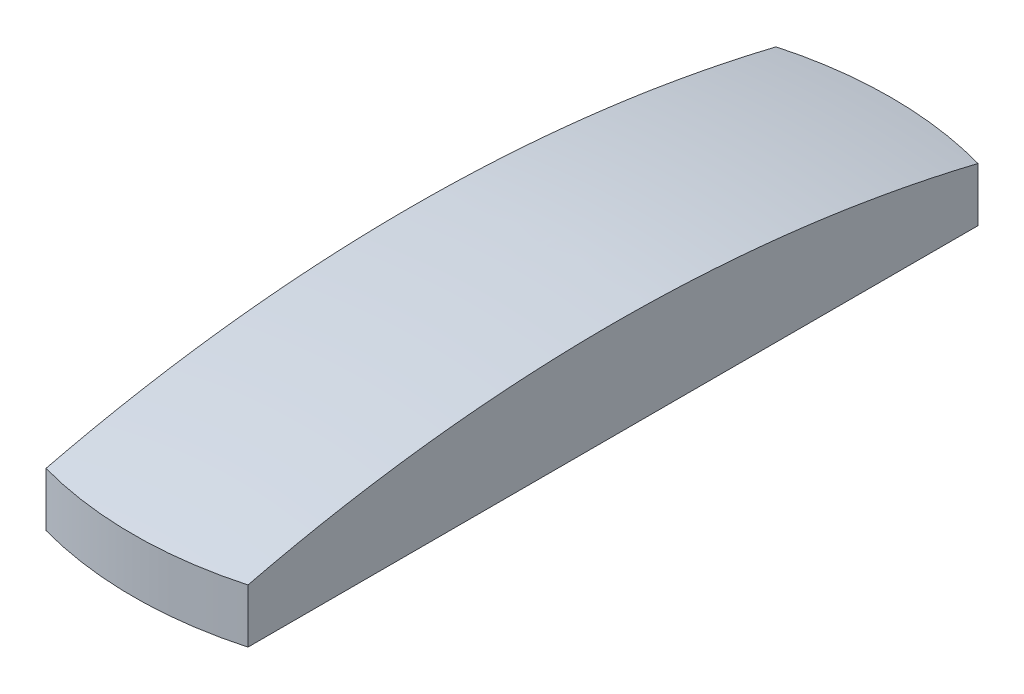
from build123d import *

# Parameters (mm, degrees)
CUT_EXTRUDE_2_DEPTH = 3


with BuildPart() as part:
    # Эскиз1 → Повернуть1 (revolve)
    with BuildSketch(Plane(origin=(0, 0, 0), x_dir=(0, 0, -1), z_dir=(1, 0, 0))):
        with BuildLine():
            Line((0, 0), (7.5, 0))
            Line((7.5, 0), (7.5, 1.06664794))
            ThreePointArc((7.5, 1.06664794), (3.778926636, 1.765765485), (0, 2))
            Line((0, 2), (0, 0))
        make_face()
    revolve(axis=Axis((0, 2, 0), (0, -1, 0)))

    # Эскиз2 → Вырез-Вытянуть2 (cut, through all)
    with BuildSketch(Plane.XZ):
        with BuildLine():
            Line((-2, -7.228416147), (-2, 7.228416147))
            ThreePointArc((-2, 7.228416147), (-7.5, 0), (-2, -7.228416147))
        make_face()
        with BuildLine():
            ThreePointArc((7.5, 0), (5.968668193, 4.541475531), (2, 7.228416147))
            Line((2, 7.228416147), (2, -7.228416147))
            ThreePointArc((2, -7.228416147), (5.968668193, -4.541475531), (7.5, 0))
        make_face()
    extrude(amount=-CUT_EXTRUDE_2_DEPTH, mode=Mode.SUBTRACT)


solid = part.part
